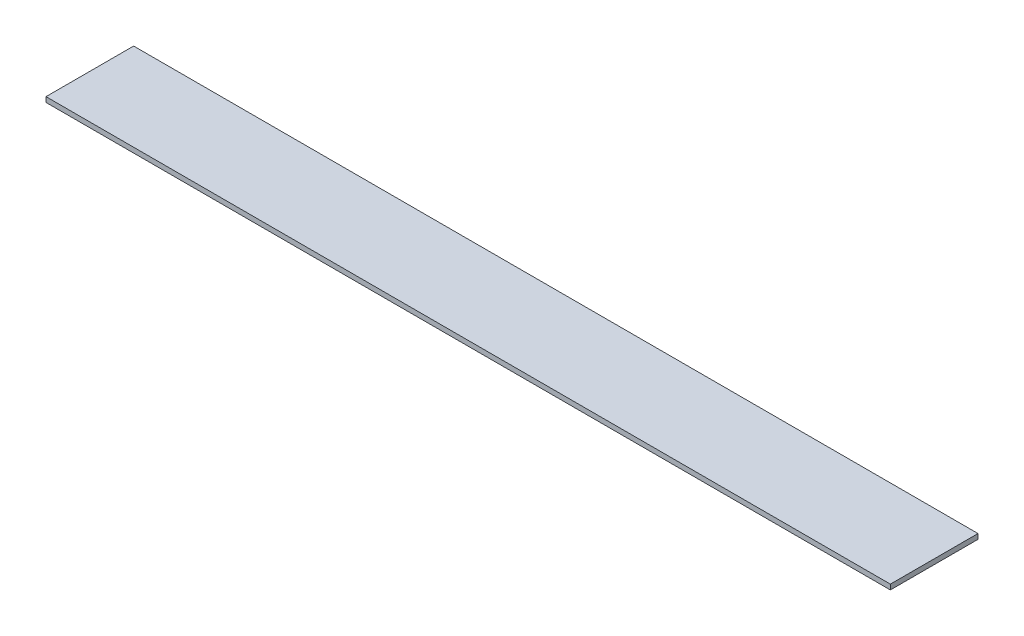
from build123d import *

# Parameters (mm, degrees)
BOSS_EXTRUDE1_DEPTH = 100


with BuildPart() as part:
    # Sketch1 → Boss-Extrude1 (new body)
    with BuildSketch(Plane(origin=(32.364284334, 0, 0), x_dir=(0, 0, -1), z_dir=(1, 0, 0))):
        Polygon((-13.365866483, 33.355059464), (-7.875866483, 33.355059464), (-7.875866483, 33.955059464), (-10.755866483, 33.955059464), (-13.365866483, 33.955059464), align=None)
        Polygon((-7.875866483, 33.955059464), (-7.875866483, 33.355059464), (-2.985866483, 33.355059464), (-2.985866483, 33.955059464), (-4.995866483, 33.955059464), align=None)
    extrude(amount=BOSS_EXTRUDE1_DEPTH)


solid = part.part
